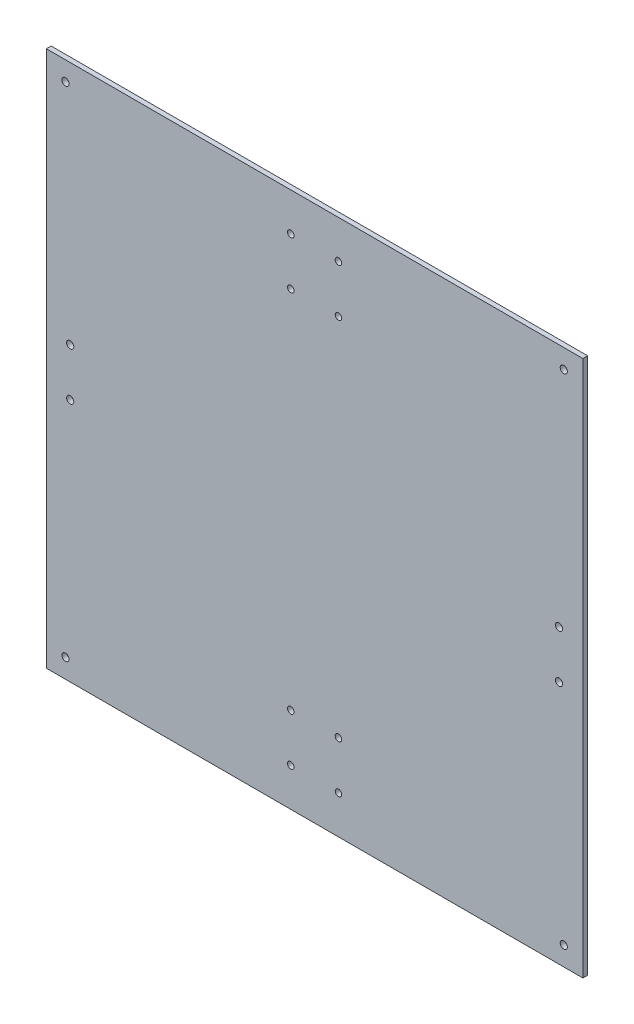
from build123d import *

# Parameters (mm, degrees)
SKETCH1_W           = 225
SKETCH1_H           = 225
SKETCH1_R           = 1.35
SKETCH1_R_2         = 1.375
SKETCH1_R_3         = 1.5
BOSS_EXTRUDE1_DEPTH = 2


with BuildPart() as part:
    # Sketch1 → Boss-Extrude1 (new body)
    with BuildSketch(Plane.XY):
        with Locations((0, -86.5)):
            Rectangle(SKETCH1_W, SKETCH1_H)
        with Locations((10, -10)):
            Circle(SKETCH1_R, mode=Mode.SUBTRACT)
        with Locations((-10, -10)):
            Circle(SKETCH1_R_2, mode=Mode.SUBTRACT)
        with Locations((-10, 10)):
            Circle(SKETCH1_R_2, mode=Mode.SUBTRACT)
        with Locations((10, 10)):
            Circle(SKETCH1_R_2, mode=Mode.SUBTRACT)
        with Locations((10, -183)):
            Circle(SKETCH1_R, mode=Mode.SUBTRACT)
        with Locations((-10, -183)):
            Circle(SKETCH1_R_2, mode=Mode.SUBTRACT)
        with Locations((-10, -163)):
            Circle(SKETCH1_R_2, mode=Mode.SUBTRACT)
        with Locations((10, -163)):
            Circle(SKETCH1_R_2, mode=Mode.SUBTRACT)
        with Locations((102.5, -76.5)):
            Circle(SKETCH1_R_3, mode=Mode.SUBTRACT)
        with Locations((102.5, -96.5)):
            Circle(SKETCH1_R_3, mode=Mode.SUBTRACT)
        with Locations((-102.5, -76.5)):
            Circle(SKETCH1_R_3, mode=Mode.SUBTRACT)
        with Locations((-102.5, -96.5)):
            Circle(SKETCH1_R_3, mode=Mode.SUBTRACT)
        with Locations((104.5, 18)):
            Circle(SKETCH1_R_3, mode=Mode.SUBTRACT)
        with Locations((104.5, -191)):
            Circle(SKETCH1_R_3, mode=Mode.SUBTRACT)
        with Locations((-104.5, -191)):
            Circle(SKETCH1_R_3, mode=Mode.SUBTRACT)
        with Locations((-104.5, 18)):
            Circle(SKETCH1_R_3, mode=Mode.SUBTRACT)
    extrude(amount=BOSS_EXTRUDE1_DEPTH)


solid = part.part
